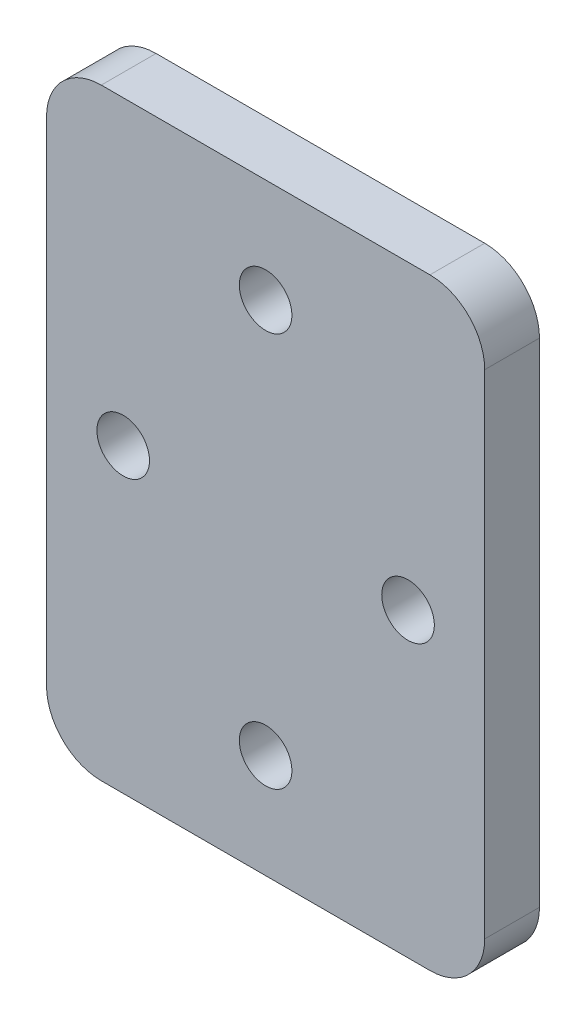
from build123d import *

# Parameters (mm, degrees)
SKETCH1_W           = 40
SKETCH1_H           = 55
SKETCH1_R           = 2.4
BOSS_EXTRUDE1_DEPTH = 5
FILLET1_R           = 5


with BuildPart() as part:
    # Sketch1 → Boss-Extrude1 (new body)
    with BuildSketch(Plane.XY):
        Rectangle(SKETCH1_W, SKETCH1_H)
        with Locations((0, 18)):
            Circle(SKETCH1_R, mode=Mode.SUBTRACT)
        with Locations((-13, 0)):
            Circle(SKETCH1_R, mode=Mode.SUBTRACT)
        with Locations((0, -18)):
            Circle(SKETCH1_R, mode=Mode.SUBTRACT)
        with Locations((13, 0)):
            Circle(SKETCH1_R, mode=Mode.SUBTRACT)
    extrude(amount=BOSS_EXTRUDE1_DEPTH)

    # Fillet1
    fillet1_edges = [part.edges().sort_by_distance(p)[0] for p in [
        (20, -27.5, 2.5),
        (-20, -27.5, 2.5),
        (-20, 27.5, 2.5),
        (20, 27.5, 2.5),
    ]]
    fillet(fillet1_edges, radius=FILLET1_R)


solid = part.part
